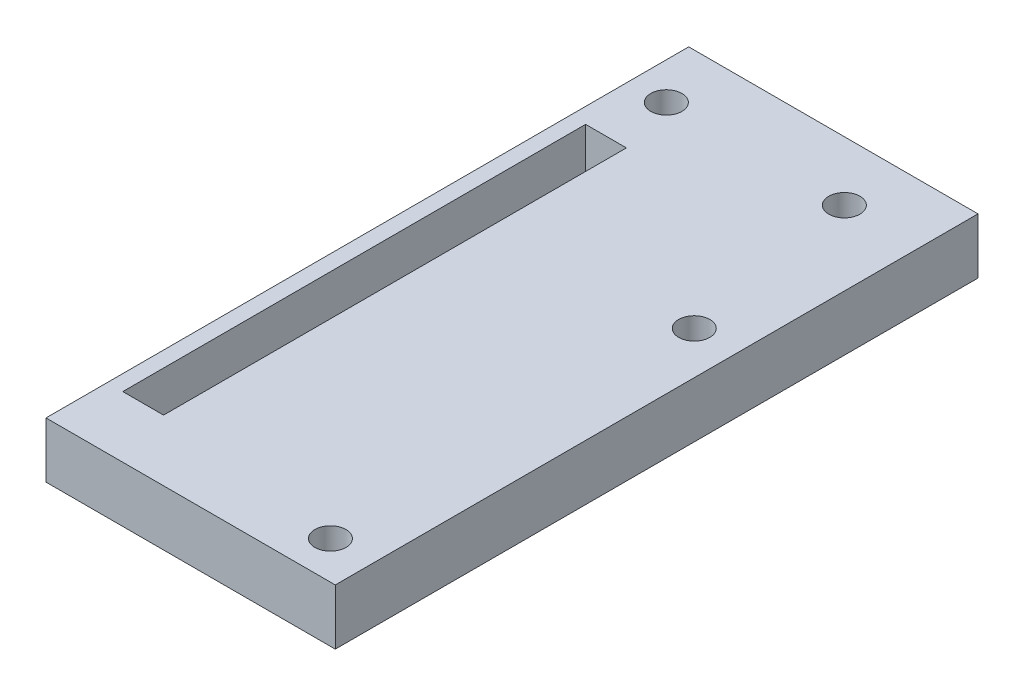
from build123d import *

# Parameters (mm, degrees)
SKETCH1_W           = 50
SKETCH1_H           = 86.65
BOSS_EXTRUDE1_DEPTH = 7.5
SKETCH7_W           = 5.5
SKETCH7_H           = 62.4
CUT_EXTRUDE5_DEPTH  = 5.95
SKETCH11_R          = 2.1
CUT_EXTRUDE8_DEPTH  = 8.5
SKETCH12_R          = 2.1
CUT_EXTRUDE10_DEPTH = 8.5
SKETCH13_W          = 86.65
SKETCH13_H          = 7.5
BOSS_EXTRUDE2_DEPTH = 1
SKETCH14_W          = 86.65
SKETCH14_H          = 7.5
CUT_EXTRUDE11_DEPTH = 12


with BuildPart() as part:
    # Sketch1 → Boss-Extrude1 (new body)
    with BuildSketch(Plane(origin=(0, 0, 0), x_dir=(1, 0, 0), z_dir=(0, 1, 0))):
        Rectangle(SKETCH1_W, SKETCH1_H)
    extrude(amount=BOSS_EXTRUDE1_DEPTH)

    # Sketch7 → Cut-Extrude5 (cut)
    with BuildSketch(Plane(origin=(0, 7.5, 0), x_dir=(1, 0, 0), z_dir=(0, 1, 0))):
        with Locations((-8.15, -3.875)):
            Rectangle(SKETCH7_W, SKETCH7_H)
    extrude(amount=-CUT_EXTRUDE5_DEPTH, mode=Mode.SUBTRACT)

    # Sketch11 → Cut-Extrude8 (cut, through all)
    with BuildSketch(Plane(origin=(0, 7.5, 0), x_dir=(1, 0, 0), z_dir=(0, 1, 0))):
        with Locations((15.982, 35.325)):
            Circle(SKETCH11_R)
        with Locations((-8.018, 35.325)):
            Circle(SKETCH11_R)
    extrude(amount=-CUT_EXTRUDE8_DEPTH, mode=Mode.SUBTRACT)

    # Sketch12 → Cut-Extrude10 (cut, through all)
    with BuildSketch(Plane(origin=(0, 7.5, 0), x_dir=(1, 0, 0), z_dir=(0, 1, 0))):
        with Locations((20.25, 10.821)):
            Circle(SKETCH12_R)
        with Locations((20.25, -38.229)):
            Circle(SKETCH12_R)
    extrude(amount=-CUT_EXTRUDE10_DEPTH, mode=Mode.SUBTRACT)

    # Sketch13 → Boss-Extrude2 (add)
    with BuildSketch(Plane(origin=(25, 0, 0), x_dir=(0, 0, -1), z_dir=(1, 0, 0))):
        with Locations((0, 3.75)):
            Rectangle(SKETCH13_W, SKETCH13_H)
    extrude(amount=BOSS_EXTRUDE2_DEPTH)

    # Sketch14 → Cut-Extrude11 (cut)
    with BuildSketch(Plane.ZY.offset(25)):
        with Locations((0, 3.75)):
            Rectangle(SKETCH14_W, SKETCH14_H)
    extrude(amount=-CUT_EXTRUDE11_DEPTH, mode=Mode.SUBTRACT)


solid = part.part
